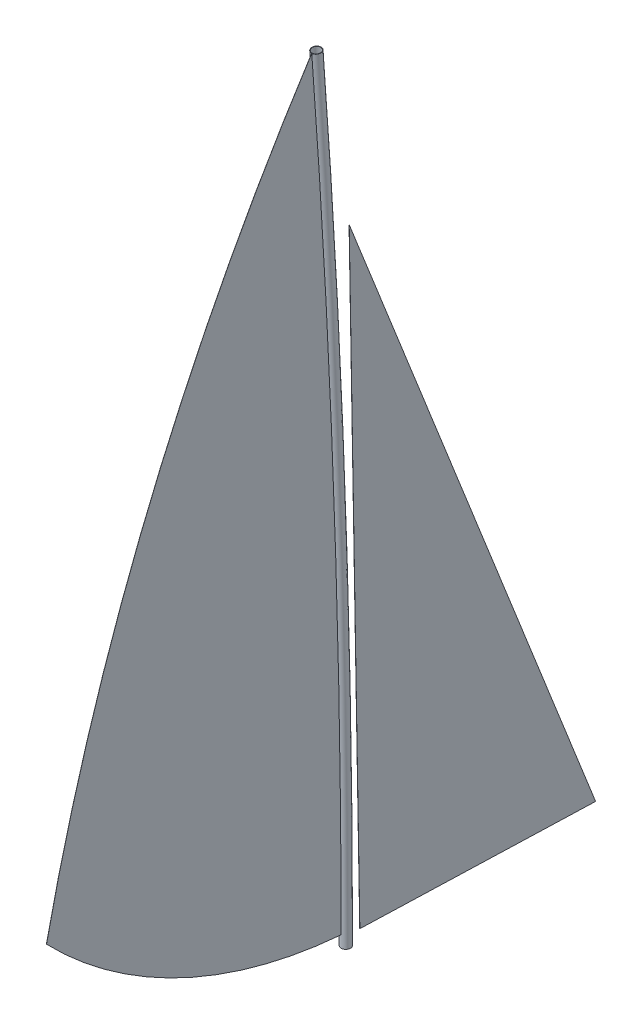
from build123d import *

# Parameters (mm, degrees)
SKETCH_1_R        = 40
SKETCH_1_R_2      = 37
EXTRUDE_1_DEPTH   = 1
EXTRUDE_1_2_DEPTH = 1


with BuildPart() as part:
    # По траектории-Тонкостенный1: sweep along a path in Эскиз3
    with BuildLine(Plane(origin=(0, 0, 0), x_dir=(0, 0, -1), z_dir=(1, 0, 0))) as sweep_1_path:
        ThreePointArc((0, 0), (-62.521739436, 3352.331278379), (-250, 6700))
    # Эскиз1 → По траектории-Тонкостенный1 (sweep)
    with BuildSketch(Plane(origin=(0, 0, 0), x_dir=(1, 0, 0), z_dir=(0, 1, 0))):
        Circle(SKETCH_1_R)
        Circle(SKETCH_1_R_2, mode=Mode.SUBTRACT)
    sweep(path=sweep_1_path.line)


with BuildPart() as body_2:
    # Эскиз4 → Бобышка-Вытянуть1 (new body)
    with BuildSketch(Plane(origin=(0, 0, 0), x_dir=(0, 0, -1), z_dir=(1, 0, 0))):
        Polygon((27.186992612, 5280.053707105), (2116.58019703, 0.591107293), (117.637669058, 65.620099767), align=None)
    extrude(amount=EXTRUDE_1_DEPTH)


with BuildPart() as body_3:
    # Эскиз4 → Extrude 1 2 (new body)
    with BuildSketch(Plane(origin=(0, 0, 0), x_dir=(0, 0, -1), z_dir=(1, 0, 0))):
        with BuildLine():
            ThreePointArc((-40.055639031, 100), (-104.372197224, 3400.804497078), (-289.888771481, 6697.019075691))
            ThreePointArc((-289.888771481, 6697.019075691), (-1659.217455567, 4090.004624299), (-2539.121344337, 1279.781405166))
            ThreePointArc((-2539.121344337, 1279.781405166), (-1397.210671567, 461.92059075), (-40.055639031, 100))
        make_face()
    extrude(amount=EXTRUDE_1_2_DEPTH)


solid = Compound([part.part, body_2.part, body_3.part])
